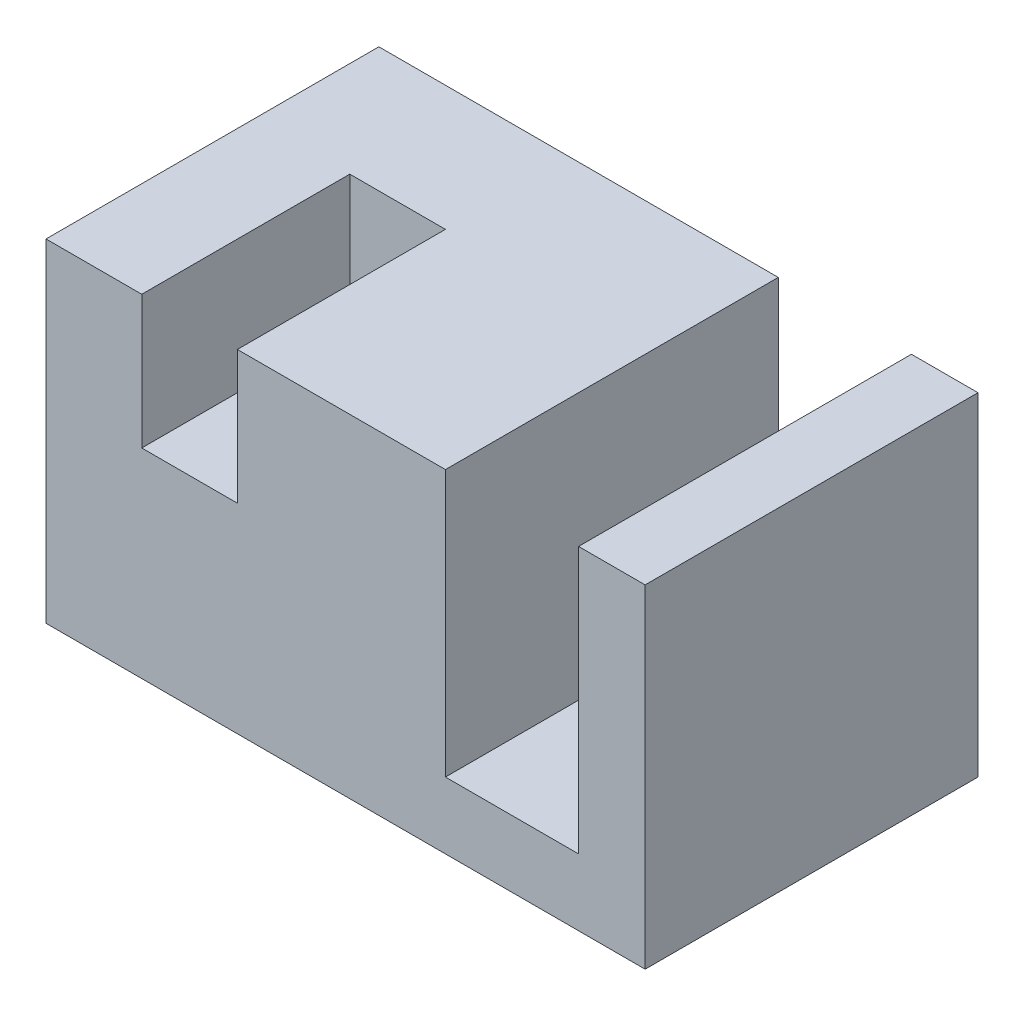
from build123d import *

# Parameters (mm, degrees)
CROQUIS1_W              = 72
CROQUIS1_H              = 40
SALIENTE_EXTRUIR1_DEPTH = 40
CROQUIS5_W              = 16
CROQUIS5_H              = 40
CORTAR_EXTRUIR3_DEPTH   = 32
CROQUIS6_W              = 11.492452947
CROQUIS6_H              = 25
CORTAR_EXTRUIR5_DEPTH   = 16


with BuildPart() as part:
    # Croquis1 → Saliente-Extruir1 (new body)
    with BuildSketch(Plane(origin=(0, 0, 0), x_dir=(1, 0, 0), z_dir=(0, 1, 0))):
        Rectangle(CROQUIS1_W, CROQUIS1_H)
    extrude(amount=SALIENTE_EXTRUIR1_DEPTH)

    # Croquis5 → Cortar-Extruir3 (cut)
    with BuildSketch(Plane(origin=(0, 40, 0), x_dir=(1, 0, 0), z_dir=(0, 1, 0))):
        with Locations((20, 0)):
            Rectangle(CROQUIS5_W, CROQUIS5_H)
    extrude(amount=-CORTAR_EXTRUIR3_DEPTH, mode=Mode.SUBTRACT)

    # Croquis6 → Cortar-Extruir5 (cut)
    with BuildSketch(Plane(origin=(0, 40, 0), x_dir=(1, 0, 0), z_dir=(0, 1, 0))):
        with Locations((-18.746226474, -7.5)):
            Rectangle(CROQUIS6_W, CROQUIS6_H)
    extrude(amount=-CORTAR_EXTRUIR5_DEPTH, mode=Mode.SUBTRACT)


solid = part.part
